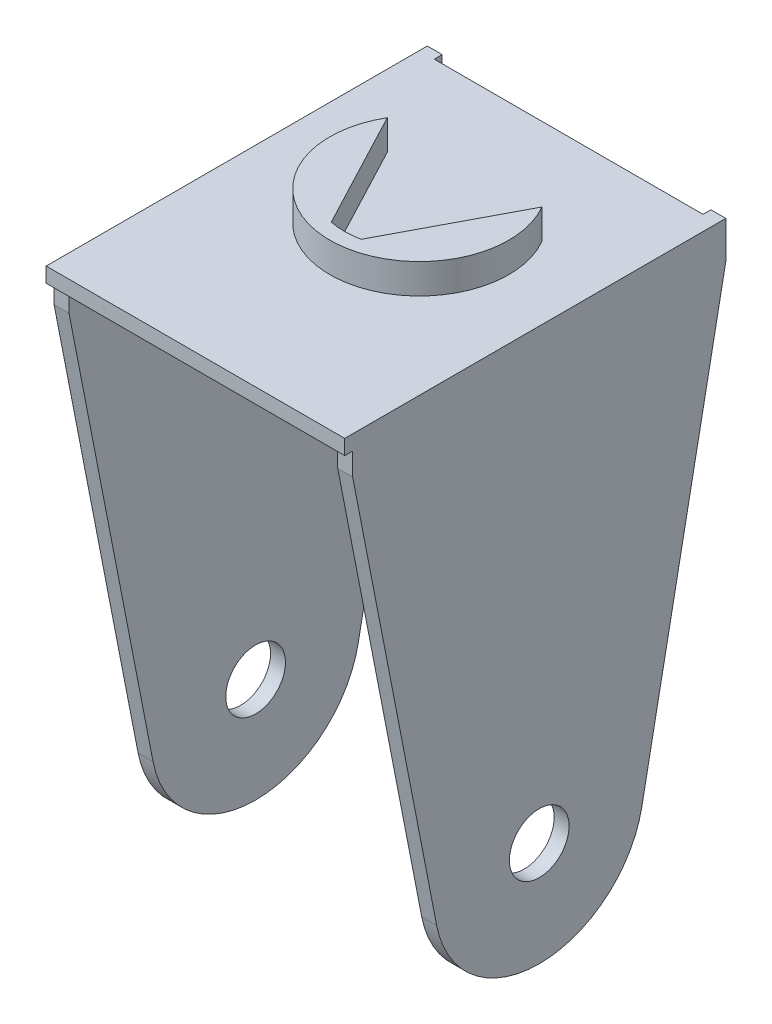
from build123d import *

# Parameters (mm, degrees)
BOSS_EXTRUDE1_DEPTH = 2
SKETCH2_W           = 40
SKETCH2_H           = 50
BOSS_EXTRUDE2_DEPTH = 2
BOSS_EXTRUDE3_DEPTH = 4
SKETCH4_R           = 4
CUT_EXTRUDE1_DEPTH  = 41


with BuildPart() as part:
    # Sketch1 → Boss-Extrude1 (new body)
    with BuildSketch(Plane(origin=(0, 0, 0), x_dir=(0, 0, -1), z_dir=(1, 0, 0))):
        with BuildLine():
            Line((-4.485924614, 52.27530577), (6.773398514, -5.406820081))
            ThreePointArc((6.773398514, -5.406820081), (20.514075386, -16.72469423), (34.254752259, -5.406820081))
            Line((34.254752259, -5.406820081), (45.514075386, 52.27530577))
            Line((45.514075386, 52.27530577), (45.514075386, 57.27530577))
            Line((45.514075386, 57.27530577), (-4.485924614, 57.27530577))
            Line((-4.485924614, 57.27530577), (-4.485924614, 52.27530577))
        make_face()
    extrude(amount=-BOSS_EXTRUDE1_DEPTH)


with BuildPart() as body_2:
    # Mirror1: mirrored copy
    add(part.part.mirror(Plane(origin=(-20, 0, 0), x_dir=(0, 0, 1), z_dir=(1, 0, 0))))


with BuildPart() as part_1:
    add(part.part)

    add(body_2.part)  # Boss-Extrude2 merges body 2
    # Sketch2 → Boss-Extrude2 (add)
    with BuildSketch(Plane(origin=(0, 57.27530577, 0), x_dir=(1, 0, 0), z_dir=(0, 1, 0))):
        with Locations((-20, 19.454333817)):
            Rectangle(SKETCH2_W, SKETCH2_H)
    extrude(amount=-BOSS_EXTRUDE2_DEPTH)

    # Sketch3 → Boss-Extrude3 (add)
    with BuildSketch(Plane(origin=(0, 57.27530577, 0), x_dir=(1, 0, 0), z_dir=(0, 1, 0))):
        with BuildLine():
            Line((-18, 14.653938589), (-9.643842411, 30.514075386))
            ThreePointArc((-9.643842411, 30.514075386), (-20, 12.45189756), (-30.356157589, 30.514075386))
            Line((-30.356157589, 30.514075386), (-22, 14.653938589))
            ThreePointArc((-22, 14.653938589), (-20, 14.45189756), (-18, 14.653938589))
        make_face()
    extrude(amount=BOSS_EXTRUDE3_DEPTH)

    # Sketch4 → Cut-Extrude1 (cut, through all)
    with BuildSketch(Plane(origin=(0, 0, 0), x_dir=(0, 0, -1), z_dir=(1, 0, 0))):
        with Locations((20.514075386, -2.72469423)):
            Circle(SKETCH4_R)
    extrude(amount=-CUT_EXTRUDE1_DEPTH, mode=Mode.SUBTRACT)


solid = part_1.part
